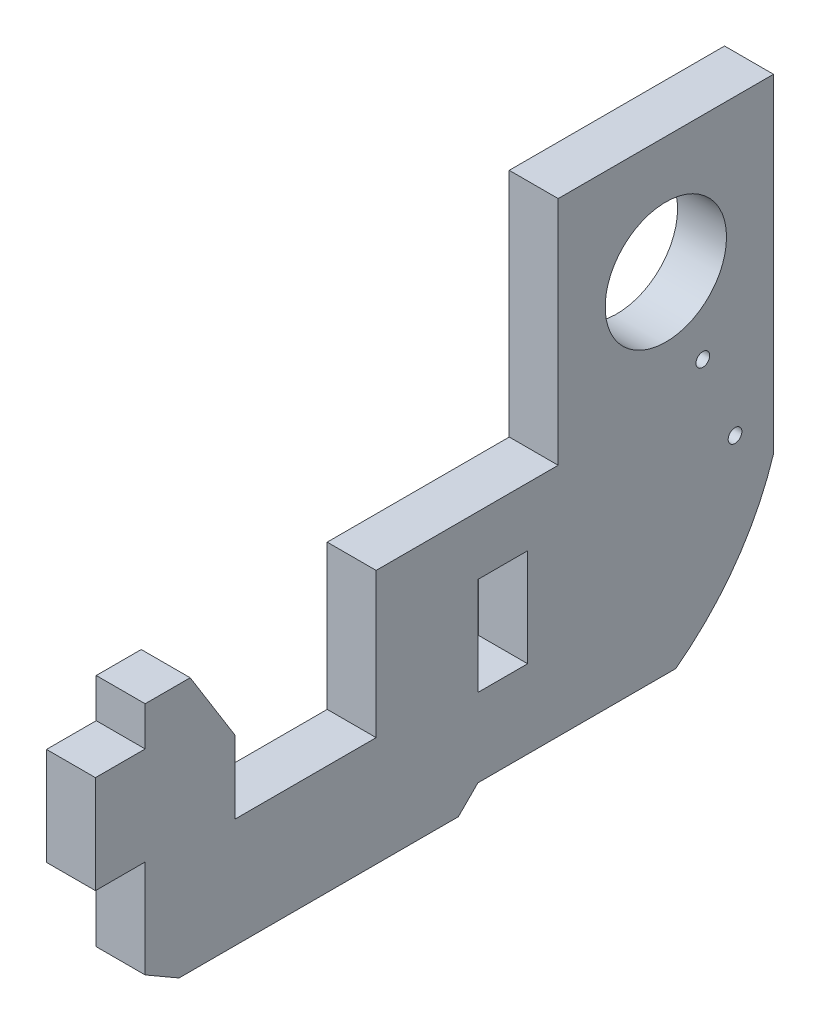
from build123d import *

# Parameters (mm, degrees)
SKETCH1_R           = 3.937
SKETCH1_R_2         = 0.4445
SKETCH1_W           = 3.2258
SKETCH1_H           = 6.35
BOSS_EXTRUDE1_DEPTH = 3.175
BOSS_EXTRUDE2_DEPTH = 3.175
CUT_EXTRUDE1_DEPTH  = 4.175


with BuildPart() as part:
    # Sketch1 → Boss-Extrude1 (new body)
    with BuildSketch(Plane(origin=(0, 0, 0), x_dir=(0, 0, -1), z_dir=(1, 0, 0))):
        Polygon((-6.985, 7.62), (6.985, 7.62), (6.985, -22.606), (-33.782, -22.606), (-33.782, -16.256), (-37.0078, -16.256), (-37.0078, -9.906), (-33.782, -9.906), (-33.782, -7.366), (-27.94, -7.366), (-27.94, -16.764), (-18.796, -16.764), (-18.796, -7.366), (-6.985, -7.366), align=None)
        Circle(SKETCH1_R, mode=Mode.SUBTRACT)
        with Locations((2.40063044, -6.111302341)):
            Circle(SKETCH1_R_2, mode=Mode.SUBTRACT)
        with Locations((4.490066454, -11.430652127)):
            Circle(SKETCH1_R_2, mode=Mode.SUBTRACT)
        with Locations((-10.5791, -14.351)):
            Rectangle(SKETCH1_W, SKETCH1_H, mode=Mode.SUBTRACT)
    extrude(amount=BOSS_EXTRUDE1_DEPTH)

    # Sketch2 → Boss-Extrude2 (add)
    with BuildSketch(Plane.ZY):
        Polygon((13.462, -23.876), (31.582295474, -23.876), (33.782, -22.606), (12.192, -22.606), align=None)
    extrude(amount=-BOSS_EXTRUDE2_DEPTH)

    # Sketch3 → Cut-Extrude1 (cut, through all)
    with BuildSketch(Plane(origin=(3.175, 0, 0), x_dir=(0, 0, -1), z_dir=(1, 0, 0))):
        Polygon((-30.861, -7.366), (-27.94, -7.366), (-27.94, -12.065), align=None)
        with BuildLine():
            Line((6.985, -13.716), (6.985, -22.606))
            Line((6.985, -22.606), (0.635, -22.606))
            ThreePointArc((0.635, -22.606), (4.50973023, -18.660807307), (6.985, -13.716))
        make_face()
    extrude(amount=-CUT_EXTRUDE1_DEPTH, mode=Mode.SUBTRACT)


solid = part.part
